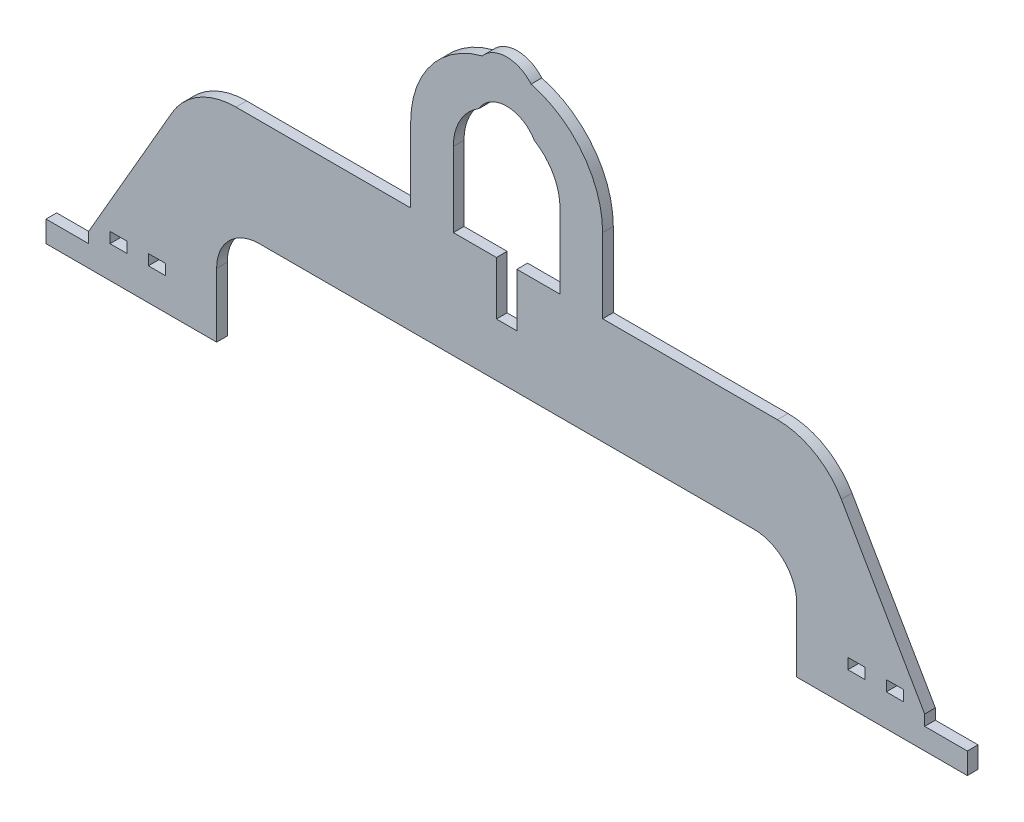
from build123d import *

# Parameters (mm, degrees)
EXTRUDE_1_DEPTH     = 5
CUT_EXTRUDE_1_REACH = 7
EXTRUDE_2_DEPTH     = 5
CUT_EXTRUDE_2_REACH = 7
SKETCH_4_W          = 9.6
SKETCH_4_H          = 50
EXTRUDE_3_DEPTH     = 5
CUT_EXTRUDE_3_REACH = 7
SKETCH_6_W          = 8
SKETCH_6_H          = 5


with BuildPart() as part:
    # 草图1 → 凸台-拉伸1 (new body)
    with BuildSketch(Plane.XY):
        Polygon((-216, 0), (-216, 10), (-196, 10), (-196, 15), (-146.925227119, 100), (146.925227119, 100), (196, 15), (196, 10), (216, 10), (216, 0), (136, 0), (136, 50), (-136, 50), (-136, 0), align=None)
    extrude(amount=EXTRUDE_1_DEPTH)

    # 草图2 → 切除-拉伸1 (cut, up to next)
    with BuildSketch(Plane.XY.offset(5), mode=Mode.PRIVATE) as cut_extrude_1_sk1:
        with BuildLine():
            Line((-146.925227119, 100), (-126.925227119, 100))
            ThreePointArc((-126.925227119, 100), (-144.245735195, 95.358983849), (-156.925227119, 82.679491924))
            Line((-156.925227119, 82.679491924), (-146.925227119, 100))
        make_face()
    cut_extrude_1_tool1 = extrude(cut_extrude_1_sk1.sketch, amount=-CUT_EXTRUDE_1_REACH, mode=Mode.PRIVATE) & part.part
    add(cut_extrude_1_tool1.solids().sort_by_distance((-144.827064, 96.365874, 5))[0], mode=Mode.SUBTRACT)
    # 草图2 → 切除-拉伸1 (cut, up to next)
    with BuildSketch(Plane.XY.offset(5), mode=Mode.PRIVATE) as cut_extrude_1_sk2:
        with BuildLine():
            Line((146.925227119, 100), (156.925227119, 82.679491924))
            ThreePointArc((156.925227119, 82.679491924), (144.245735195, 95.358983849), (126.925227119, 100))
            Line((126.925227119, 100), (146.925227119, 100))
        make_face()
    cut_extrude_1_tool2 = extrude(cut_extrude_1_sk2.sketch, amount=-CUT_EXTRUDE_1_REACH, mode=Mode.PRIVATE) & part.part
    add(cut_extrude_1_tool2.solids().sort_by_distance((144.827064, 96.365874, 5))[0], mode=Mode.SUBTRACT)

    # 草图3 → 凸台-拉伸2 (add)
    with BuildSketch(Plane.XY.offset(5)):
        with BuildLine():
            Line((-116, 50), (-136, 50))
            Line((-136, 50), (-136, 30))
            ThreePointArc((-136, 30), (-130.142135624, 44.142135624), (-116, 50))
        make_face()
        with BuildLine():
            Line((136, 50), (136, 30))
            ThreePointArc((136, 30), (130.142135624, 44.142135624), (116, 50))
            Line((116, 50), (136, 50))
        make_face()
    extrude(amount=-EXTRUDE_2_DEPTH)

    # 草图4 → 切除-拉伸2 (cut, up to next)
    with BuildSketch(Plane.XY.offset(5), mode=Mode.PRIVATE) as cut_extrude_2_sk1:
        with Locations((0, 100)):
            Rectangle(SKETCH_4_W, SKETCH_4_H)
    cut_extrude_2_tool1 = extrude(cut_extrude_2_sk1.sketch, amount=-CUT_EXTRUDE_2_REACH, mode=Mode.PRIVATE) & part.part
    add(cut_extrude_2_tool1.solids().sort_by_distance((0, 100, 5))[0], mode=Mode.SUBTRACT)

    # 草图5 → 凸台-拉伸3 (add)
    with BuildSketch(Plane(origin=(0, 0, 0), x_dir=(-1, 0, 0), z_dir=(0, 0, -1))):
        with BuildLine():
            Line((45, 100), (45, 135))
            ThreePointArc((45, 135), (35.642806819, 162.469807463), (11.462652354, 178.515601811))
            ThreePointArc((11.462652354, 178.515601811), (0, 183.840499693), (-11.462652354, 178.515601811))
            ThreePointArc((-11.462652354, 178.515601811), (-35.642806819, 162.469807463), (-45, 135))
            Line((-45, 135), (-45, 100))
            Line((-45, 100), (-25, 100))
            Line((-25, 100), (-25, 135))
            ThreePointArc((-25, 135), (-21.786738765, 147.261240312), (-12.97295888, 156.370595169))
            ThreePointArc((-12.97295888, 156.370595169), (0, 163.840499693), (12.97295888, 156.370595169))
            ThreePointArc((12.97295888, 156.370595169), (21.786738765, 147.261240312), (25, 135))
            Line((25, 135), (25, 100))
            Line((25, 100), (45, 100))
        make_face()
    extrude(amount=-EXTRUDE_3_DEPTH)

    # 草图6 → 切除-拉伸3 (cut, up to next)
    with BuildSketch(Plane.XY.offset(5), mode=Mode.PRIVATE) as cut_extrude_3_sk1:
        with Locations((-182, 17.5)):
            Rectangle(SKETCH_6_W, SKETCH_6_H)
    cut_extrude_3_tool1 = extrude(cut_extrude_3_sk1.sketch, amount=-CUT_EXTRUDE_3_REACH, mode=Mode.PRIVATE) & part.part
    add(cut_extrude_3_tool1.solids().sort_by_distance((-182, 17.5, 5))[0], mode=Mode.SUBTRACT)
    # 草图6 → 切除-拉伸3 (cut, up to next)
    with BuildSketch(Plane.XY.offset(5), mode=Mode.PRIVATE) as cut_extrude_3_sk2:
        with Locations((-164, 17.5)):
            Rectangle(SKETCH_6_W, SKETCH_6_H)
    cut_extrude_3_tool2 = extrude(cut_extrude_3_sk2.sketch, amount=-CUT_EXTRUDE_3_REACH, mode=Mode.PRIVATE) & part.part
    add(cut_extrude_3_tool2.solids().sort_by_distance((-164, 17.5, 5))[0], mode=Mode.SUBTRACT)
    # 草图6 → 切除-拉伸3 (cut, up to next)
    with BuildSketch(Plane.XY.offset(5), mode=Mode.PRIVATE) as cut_extrude_3_sk3:
        with Locations((182, 17.5)):
            Rectangle(SKETCH_6_W, SKETCH_6_H)
    cut_extrude_3_tool3 = extrude(cut_extrude_3_sk3.sketch, amount=-CUT_EXTRUDE_3_REACH, mode=Mode.PRIVATE) & part.part
    add(cut_extrude_3_tool3.solids().sort_by_distance((182, 17.5, 5))[0], mode=Mode.SUBTRACT)
    # 草图6 → 切除-拉伸3 (cut, up to next)
    with BuildSketch(Plane.XY.offset(5), mode=Mode.PRIVATE) as cut_extrude_3_sk4:
        with Locations((164, 17.5)):
            Rectangle(SKETCH_6_W, SKETCH_6_H)
    cut_extrude_3_tool4 = extrude(cut_extrude_3_sk4.sketch, amount=-CUT_EXTRUDE_3_REACH, mode=Mode.PRIVATE) & part.part
    add(cut_extrude_3_tool4.solids().sort_by_distance((164, 17.5, 5))[0], mode=Mode.SUBTRACT)


solid = part.part
